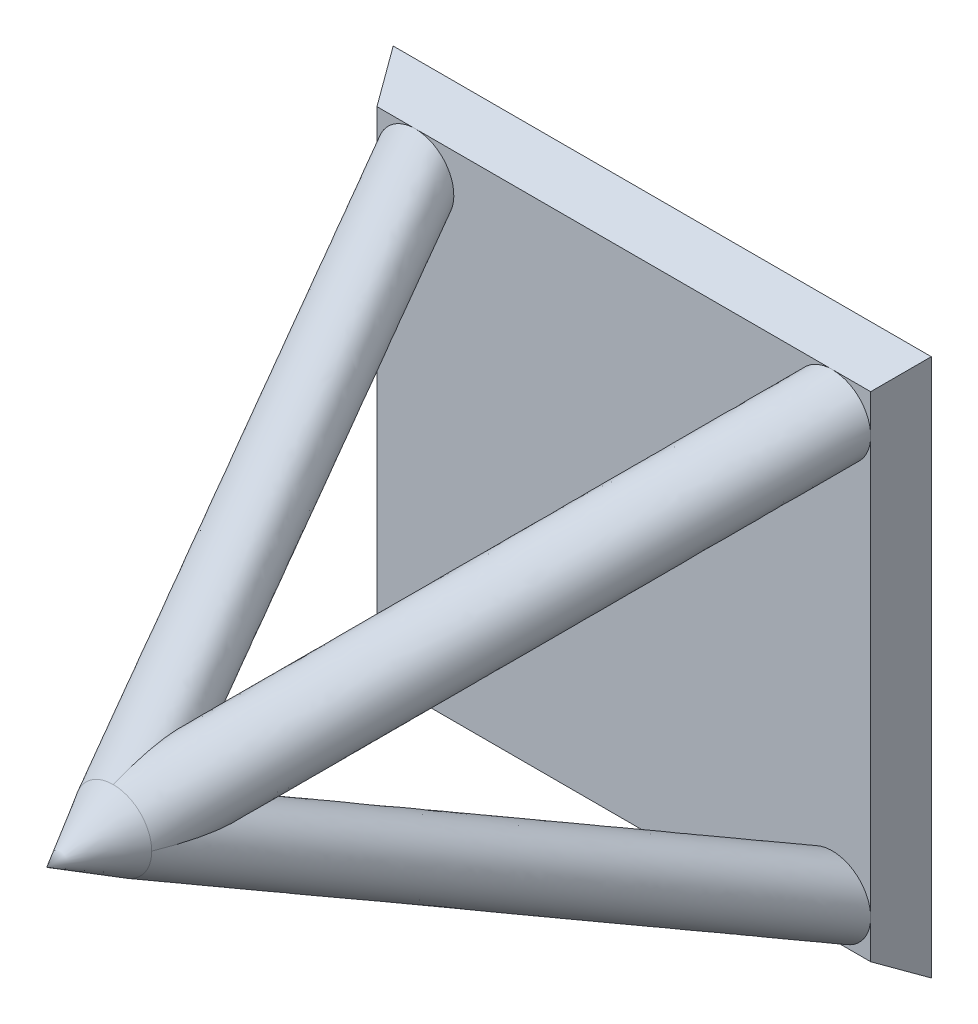
from build123d import *

# Parameters (mm, degrees)
SKETCH1_W           = 14
SKETCH1_H           = 14
BOSS_EXTRUDE1_DEPTH = 1
BOSS_EXTRUDE1_TAPER = 30
SKETCH2_R           = 1
CIRPATTERN1_COUNT   = 4
SKETCH4_R           = 1
BOSS_EXTRUDE2_DEPTH = 10
BOSS_EXTRUDE2_TAPER = 30


with BuildPart() as part:
    # Sketch1 → Boss-Extrude1 (new body)
    with BuildSketch(Plane.XY):
        Rectangle(SKETCH1_W, SKETCH1_H)
    extrude(amount=BOSS_EXTRUDE1_DEPTH, taper=BOSS_EXTRUDE1_TAPER)

    # Sweep1: sweep along a path in Sketch3
    with BuildLine(Plane(origin=(0, 0, 0), x_dir=(0, 0, -1), z_dir=(0.7071067811865476, -0.7071067811865475, 0))) as sweep1_path:
        Line((-1, 7.668784793), (-14.282724894, 0))
    # Sketch2 → Sweep1 (sweep)
    with BuildSketch(Plane.XY.offset(1)):
        with Locations((5.422649731, 5.422649731)):
            Circle(SKETCH2_R)
    sweep1 = sweep(path=sweep1_path.line)

    # CirPattern1: Sweep1 ×4 about axis
    cirpattern1_axis = Axis((0, 0, -4.23184126), (0, 0, 1))
    for i in range(1, CIRPATTERN1_COUNT):
        add(sweep1.rotate(cirpattern1_axis, i * 360 / CIRPATTERN1_COUNT))

    # Sketch4 → Boss-Extrude2 (add)
    with BuildSketch(Plane.XY.offset(14.282724894)):
        Circle(SKETCH4_R)
    extrude(amount=BOSS_EXTRUDE2_DEPTH, taper=BOSS_EXTRUDE2_TAPER)


solid = part.part
